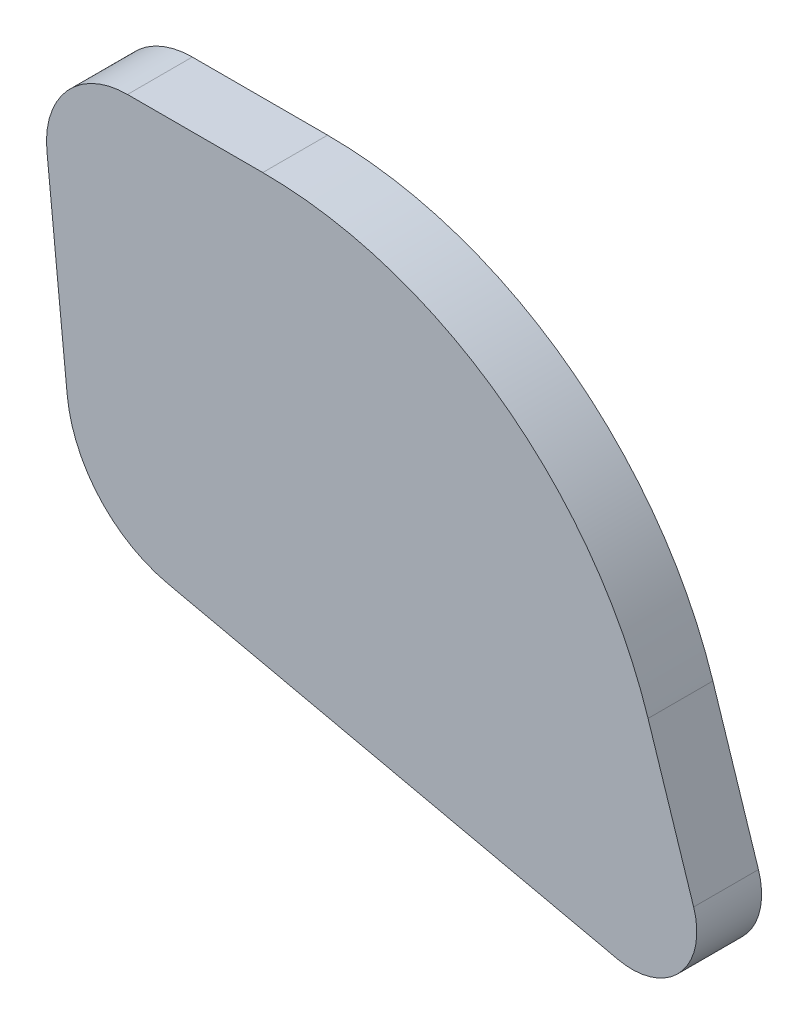
from build123d import *

# Parameters (mm, degrees)
BOSS_EXTRUDE1_DEPTH = 4
SCALE1_SCALE        = 0.709677419
SCALE2_SCALE        = 1.107011


with BuildPart() as part:
    # Sketch1 → Boss-Extrude1 (new body)
    with BuildSketch(Plane.XY):
        with BuildLine():
            Line((147.518542688, 207.036750067), (155.868006274, 207.036750067))
            ThreePointArc((155.868006274, 207.036750067), (170.568083888, 202.258216832), (179.648576747, 189.749367518))
            Line((179.648576747, 189.749367518), (182.461666016, 181.075675605))
            ThreePointArc((182.461666016, 181.075675605), (181.615221362, 177.149521305), (177.786078934, 175.937570644))
            Line((177.786078934, 175.937570644), (150.012503839, 182.131679667))
            ThreePointArc((150.012503839, 182.131679667), (145.770913066, 184.629115543), (143.794281074, 189.137020178))
            Line((143.794281074, 189.137020178), (142.543783701, 201.534980175))
            ThreePointArc((142.543783701, 201.534980175), (143.809846862, 205.390192369), (147.518542688, 207.036750067))
        make_face()
    extrude(amount=BOSS_EXTRUDE1_DEPTH)


with BuildPart() as part_1:
    # Scale1: scaled about (161.61313874, 191.864088439, 2)
    add(part.part.scale(SCALE1_SCALE).moved(Location((46.919943505, 55.702477289, 0.580645161))))


with BuildPart() as part_2:
    # Scale2: scaled about (161.61313874, 191.864088439, 2)
    add(part_1.part.scale(SCALE2_SCALE).moved(Location((-17.29438359, -20.531567968, -0.214022))))


solid = part_2.part
